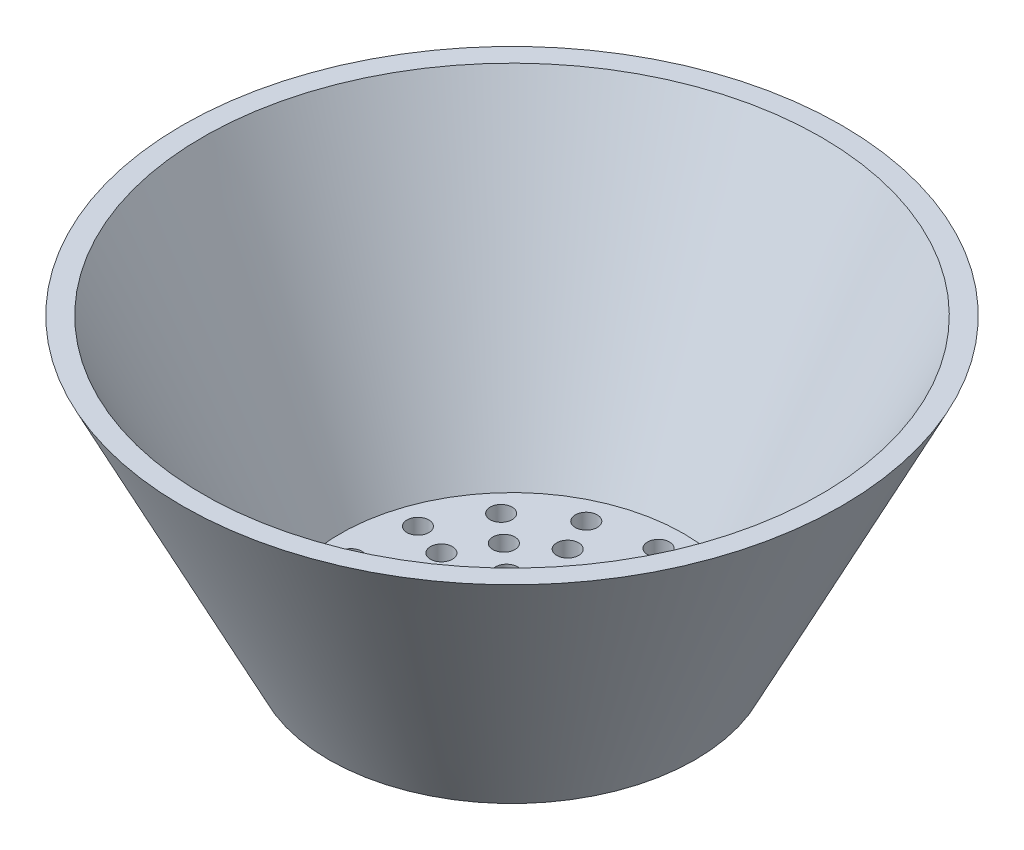
from build123d import *

# Parameters (mm, degrees)
SKETCH3_R          = 3
CUT_EXTRUDE5_DEPTH = 10
CIRPATTERN2_COUNT  = 15
SKETCH4_R          = 3
SKETCH4_R_2        = 2
CUT_EXTRUDE7_DEPTH = 10
CIRPATTERN3_COUNT  = 15


with BuildPart() as part:
    # Sketch1 → Revolve1 (revolve)
    with BuildSketch(Plane.XY):
        Polygon((90, 80), (50, 0), (0, 0), (0, 5), (5, 5), (46.909830056, 5), (81.909830056, 75), (84.409830056, 80), align=None)
    revolve(axis=Axis((0, 0, 0), (0, 1, 0)))

    # Sketch3 → Cut-Extrude5 (cut)
    with BuildSketch(Plane(origin=(0, 5, 0), x_dir=(1, 0, 0), z_dir=(0, 1, 0))):
        with Locations((0, 40)):
            Circle(SKETCH3_R)
    cut_extrude5 = extrude(amount=-CUT_EXTRUDE5_DEPTH, mode=Mode.SUBTRACT)

    # CirPattern2: Cut-Extrude5 ×15 about axis
    cirpattern2_axis = Axis((0, 0, 0), (0, 1, 0))
    for i in range(1, CIRPATTERN2_COUNT):
        add(cut_extrude5.rotate(cirpattern2_axis, i * 360 / CIRPATTERN2_COUNT), mode=Mode.SUBTRACT)

    # Sketch4 → Cut-Extrude7 (cut)
    with BuildSketch(Plane(origin=(0, 5, 0), x_dir=(1, 0, 0), z_dir=(0, 1, 0))):
        with Locations((0, 30)):
            Circle(SKETCH4_R)
        with Locations((0, 20)):
            Circle(SKETCH4_R)
        Circle(SKETCH4_R_2)
        with Locations((0, 10)):
            Circle(SKETCH4_R_2)
    cut_extrude7 = extrude(amount=-CUT_EXTRUDE7_DEPTH, mode=Mode.SUBTRACT)

    # CirPattern3: Cut-Extrude7 ×15 about axis
    cirpattern3_axis = Axis((0, 0, 0), (0, 1, 0))
    for i in range(1, CIRPATTERN3_COUNT):
        add(cut_extrude7.rotate(cirpattern3_axis, i * 360 / CIRPATTERN3_COUNT), mode=Mode.SUBTRACT)


solid = part.part
